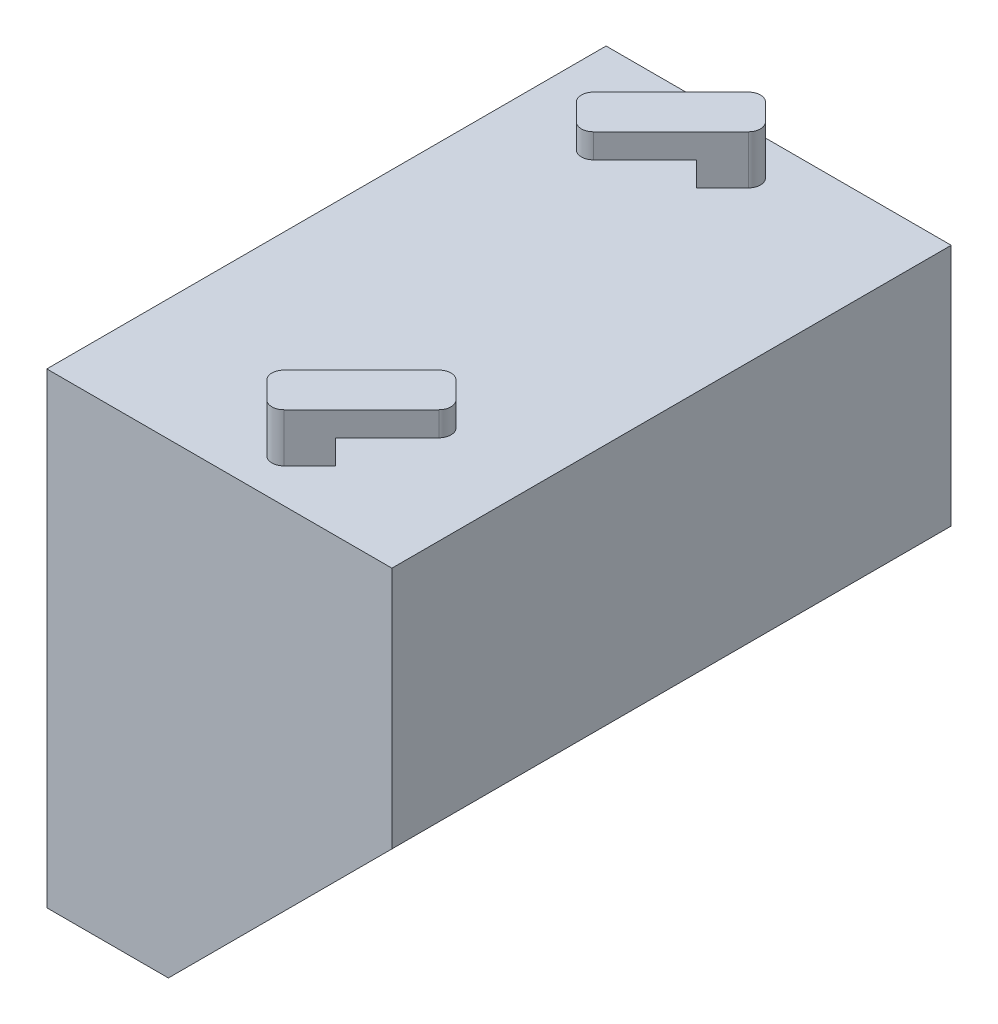
from build123d import *

# Parameters (mm, degrees)
BOSS_EXTRU_1_DEPTH                  = 22
BOSS_EXTRU_1_DEPTH_BACK             = 22
BOSS_EXTRU_5_START                  = 22
BOSS_EXTRU_5_DEPTH                  = 1
BOSS_EXTRU_6_START                  = -22
BOSS_EXTRU_6_DEPTH                  = 1
BOSS_EXTRU_7_DEPTH                  = 2
BOSS_EXTRU_8_DEPTH                  = 2
CONG_1_R                            = 1
ENL_V_MAT_EXTRU_1_REACH             = 59.63
ESQUISSE6_R                         = 0.75
ESQUISSE6_W                         = 23.5
ESQUISSE6_H                         = 23.5
ENL_V_MAT_EXTRU_1_DIRECTION_2_DEPTH = 2


with BuildPart() as part:
    # Esquisse1 → Boss.-Extru.1 (new, two sides: drawn at the far end of the back side and taken through both)
    with BuildSketch(Plane.XY.offset(-BOSS_EXTRU_1_DEPTH_BACK)):
        Polygon((0, 38.384776311), (28.384776311, 38.384776311), (28.384776311, 18.384776311), (10, 0), (0, 0), (0, 1), (9.585786438, 1), (27.384776311, 18.798989873), (27.384776311, 37.384776311), (0, 37.384776311), align=None)
    extrude(amount=BOSS_EXTRU_1_DEPTH + BOSS_EXTRU_1_DEPTH_BACK)

    # Esquisse2 → Boss.-Extru.5 (add)
    with BuildSketch(Plane.XY.offset(BOSS_EXTRU_5_START)):
        Polygon((28.384776311, 38.384776311), (0, 38.384776311), (0, 0), (10, 0), (28.384776311, 18.384776311), align=None)
    extrude(amount=BOSS_EXTRU_5_DEPTH)

    # Esquisse3 → Boss.-Extru.6 (add)
    with BuildSketch(Plane.XY.offset(BOSS_EXTRU_6_START)):
        Polygon((0, 38.384776311), (0, 0), (10, 0), (28.384776311, 18.384776311), (28.384776311, 38.384776311), align=None)
    extrude(amount=-BOSS_EXTRU_6_DEPTH)

    # Esquisse4 → Boss.-Extru.7 (add)
    with BuildSketch(Plane(origin=(0, 38.384776311, 0), x_dir=(1, 0, 0), z_dir=(0, 1, 0))):
        Polygon((11.01040764, 19.445436483), (13.838834765, 16.617009358), (16.66726189, 19.445436483), (13.838834765, 22.273863607), align=None)
        Polygon((15.960155108, -20.859650045), (18.788582233, -18.03122292), (15.960155108, -15.202795796), (13.131727984, -18.03122292), align=None)
    extrude(amount=BOSS_EXTRU_7_DEPTH)

    # Esquisse5 → Boss.-Extru.8 (add)
    with BuildSketch(Plane(origin=(0, 40.384776311, 0), x_dir=(1, 0, 0), z_dir=(0, 1, 0))):
        Polygon((13.838834765, 22.273863607), (16.66726189, 19.445436483), (8.889087297, 11.66726189), (6.060660172, 14.495689014), align=None)
        Polygon((13.131727984, -18.03122292), (15.960155108, -20.859650045), (23.738329701, -13.081475452), (20.909902577, -10.253048327), align=None)
    extrude(amount=BOSS_EXTRU_8_DEPTH)

    # Congé1
    cong_1_edges = [part.edges().sort_by_distance(p)[0] for p in [
        (20.909902577, 41.384776311, 10.253048327),
        (23.738329701, 41.384776311, 13.081475452),
        (6.060660172, 41.384776311, -14.495689014),
        (8.889087297, 41.384776311, -11.66726189),
        (13.838834765, 40.384776311, -22.273863607),
        (16.66726189, 40.384776311, -19.445436483),
        (13.131727984, 40.384776311, 18.03122292),
        (15.960155108, 40.384776311, 20.859650045),
    ]]
    fillet(cong_1_edges, radius=CONG_1_R)

    # Esquisse6 → Enlèv. mat.-Extru.1 (cut, up to next)
    with BuildSketch(Plane(origin=(5, -5, 0), x_dir=(0, 0, -1), z_dir=(0.707106781186549, -0.707106781186546, 0)), mode=Mode.PRIVATE) as enl_v_mat_extru_1_sk1:
        with Locations((14.25, 20.071067812)):
            Circle(ESQUISSE6_R)
    enl_v_mat_extru_1_tool1 = extrude(enl_v_mat_extru_1_sk1.sketch, amount=-ENL_V_MAT_EXTRU_1_REACH, mode=Mode.PRIVATE) & part.part
    # Esquisse6 → Enlèv. mat.-Extru.1 (cut, up to next)
    with BuildSketch(Plane(origin=(5, -5, 0), x_dir=(0, 0, -1), z_dir=(0.707106781186549, -0.707106781186546, 0)), mode=Mode.PRIVATE) as enl_v_mat_extru_1_sk2:
        with Locations((-14.25, 20.071067812)):
            Circle(ESQUISSE6_R)
    enl_v_mat_extru_1_tool2 = extrude(enl_v_mat_extru_1_sk2.sketch, amount=-ENL_V_MAT_EXTRU_1_REACH, mode=Mode.PRIVATE) & part.part
    # Esquisse6 → Enlèv. mat.-Extru.1 (cut, up to next)
    with BuildSketch(Plane(origin=(5, -5, 0), x_dir=(0, 0, -1), z_dir=(0.707106781186549, -0.707106781186546, 0)), mode=Mode.PRIVATE) as enl_v_mat_extru_1_sk3:
        with Locations((0, 20.071067812)):
            Rectangle(ESQUISSE6_W, ESQUISSE6_H)
    enl_v_mat_extru_1_tool3 = extrude(enl_v_mat_extru_1_sk3.sketch, amount=-ENL_V_MAT_EXTRU_1_REACH, mode=Mode.PRIVATE) & part.part
    add(enl_v_mat_extru_1_tool1.solids().sort_by_distance((19.192388, 9.192388, -14.25))[0], mode=Mode.SUBTRACT)
    add(enl_v_mat_extru_1_tool2.solids().sort_by_distance((19.192388, 9.192388, 14.25))[0], mode=Mode.SUBTRACT)
    add(enl_v_mat_extru_1_tool3.solids().sort_by_distance((19.192388, 9.192388, 0))[0], mode=Mode.SUBTRACT)

    # Esquisse6 → Enlèv. mat.-Extru.1 direction 2 (cut)
    with BuildSketch(Plane(origin=(5, -5, 0), x_dir=(0, 0, -1), z_dir=(0.707106781186549, -0.707106781186546, 0))):
        with Locations((14.25, 20.071067812)):
            Circle(ESQUISSE6_R)
        with Locations((-14.25, 20.071067812)):
            Circle(ESQUISSE6_R)
        with Locations((0, 20.071067812)):
            Rectangle(ESQUISSE6_W, ESQUISSE6_H)
    extrude(amount=ENL_V_MAT_EXTRU_1_DIRECTION_2_DEPTH, mode=Mode.SUBTRACT)


solid = part.part
